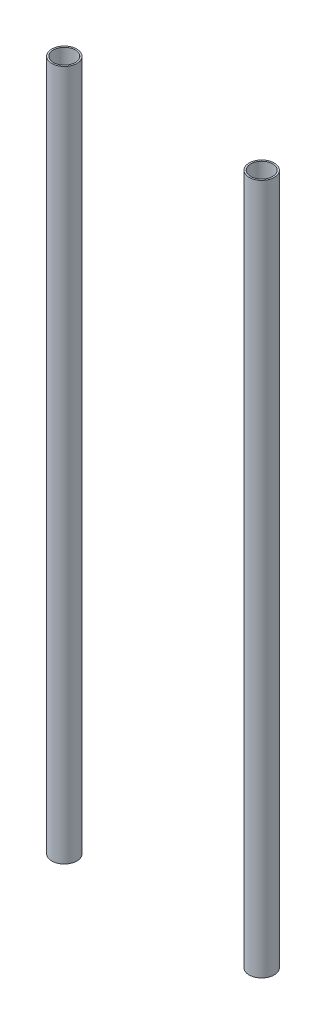
from build123d import *

# Parameters (mm, degrees)
SKETCH1_R             = 12.7
SKETCH1_R_2           = 11.1
BOSS_EXTRUDE1_DEPTH   = 700
BOSS_EXTRUDE1_2_DEPTH = 700


with BuildPart() as part:
    # Sketch1 → Boss-Extrude1 (new body)
    with BuildSketch(Plane(origin=(0, 0, 0), x_dir=(1, 0, 0), z_dir=(0, 1, 0))):
        with Locations((-100, 0)):
            Circle(SKETCH1_R)
        with Locations((-100, 0)):
            Circle(SKETCH1_R_2, mode=Mode.SUBTRACT)
    extrude(amount=BOSS_EXTRUDE1_DEPTH)


with BuildPart() as body_2:
    # Sketch1 → Boss-Extrude1 2 (new body)
    with BuildSketch(Plane(origin=(0, 0, 0), x_dir=(1, 0, 0), z_dir=(0, 1, 0))):
        with Locations((100, 0)):
            Circle(SKETCH1_R)
        with Locations((100, 0)):
            Circle(SKETCH1_R_2, mode=Mode.SUBTRACT)
    extrude(amount=BOSS_EXTRUDE1_2_DEPTH)


solid = Compound([part.part, body_2.part])
